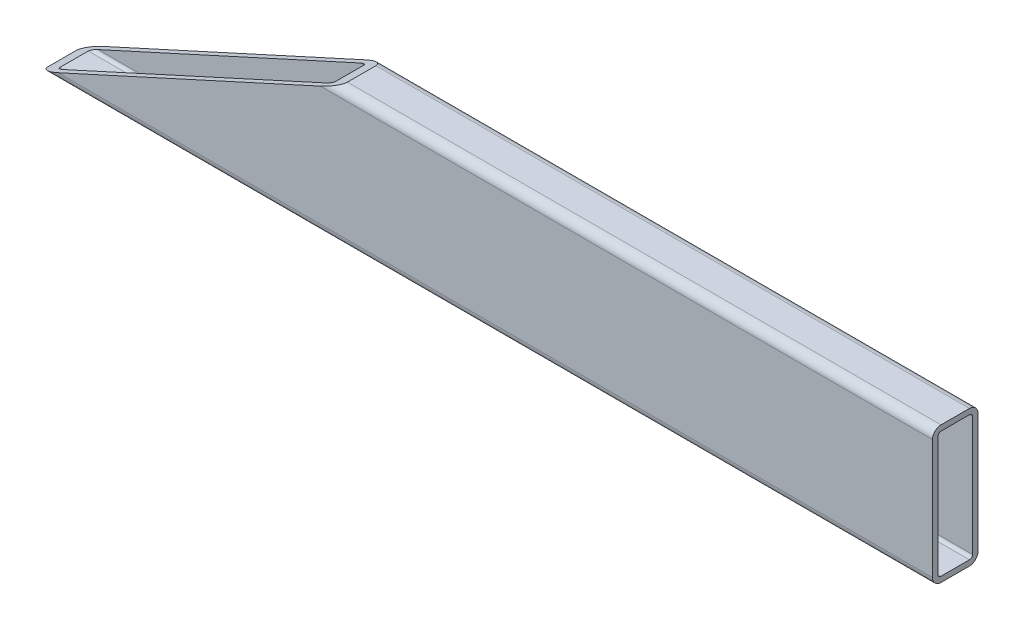
from build123d import *

# Parameters (mm, degrees)
RECTANGULAR_TUBE_3_X_2_X_0_25_1_DEPTH = 498.475
CUT_EXTRUDE1_DEPTH                    = 254.408960785


with BuildPart() as part:
    # Sketch13 → Rectangular tube 3 X 2 X 0.25(1) (new body)
    with BuildSketch(Plane.ZY.offset(-249.2375)):
        with BuildLine():
            Line((-7.9375, -38.1), (7.9375, -38.1))
            ThreePointArc((7.9375, -38.1), (11.305096045, -36.705096045), (12.7, -33.3375))
            Line((12.7, -33.3375), (12.7, 33.3375))
            ThreePointArc((12.7, 33.3375), (11.305096045, 36.705096045), (7.9375, 38.1))
            Line((7.9375, 38.1), (-7.9375, 38.1))
            ThreePointArc((-7.9375, 38.1), (-11.305096045, 36.705096045), (-12.7, 33.3375))
            Line((-12.7, 33.3375), (-12.7, -33.3375))
            ThreePointArc((-12.7, -33.3375), (-11.305096045, -36.705096045), (-7.9375, -38.1))
        make_face()
        with BuildLine():
            Line((-7.9375, -35.052), (7.9375, -35.052))
            ThreePointArc((7.9375, -35.052), (9.149834576, -34.549834576), (9.652, -33.3375))
            Line((9.652, -33.3375), (9.652, 33.3375))
            ThreePointArc((9.652, 33.3375), (9.149834576, 34.549834576), (7.9375, 35.052))
            Line((7.9375, 35.052), (-7.9375, 35.052))
            ThreePointArc((-7.9375, 35.052), (-9.149834576, 34.549834576), (-9.652, 33.3375))
            Line((-9.652, 33.3375), (-9.652, -33.3375))
            ThreePointArc((-9.652, -33.3375), (-9.149834576, -34.549834576), (-7.9375, -35.052))
        make_face(mode=Mode.SUBTRACT)
    extrude(amount=RECTANGULAR_TUBE_3_X_2_X_0_25_1_DEPTH)

    # s → Cut-Extrude1 (cut, through all)
    with BuildSketch(Plane.XY.offset(12.7)):
        Polygon((-249.2375, -38.1), (-249.2375, 38.1), (-82.031860485, 38.1), align=None)
    extrude(amount=-CUT_EXTRUDE1_DEPTH, mode=Mode.SUBTRACT)


solid = part.part
